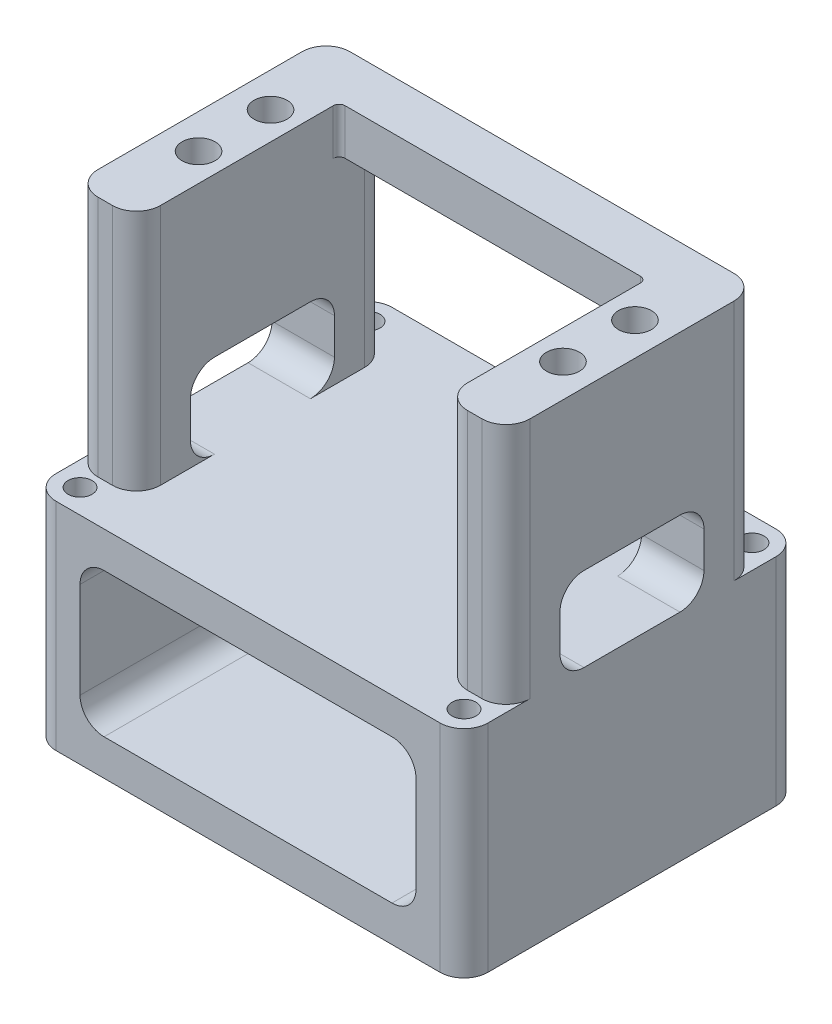
from build123d import *

# Parameters (mm, degrees)
SKETCH1_W           = 57.15
SKETCH1_H           = 38.1
SKETCH1_W_2         = 40.64
SKETCH1_H_2         = 26.035
BOSS_EXTRUDE1_DEPTH = 16.66875
CUT_EXTRUDE1_DEPTH  = 30.95625
SKETCH5_W           = 19.05
SKETCH5_H           = 11.1125
CUT_EXTRUDE2_DEPTH  = 57.15
SKETCH6_R           = 2.1828125
CUT_EXTRUDE3_DEPTH  = 19.05
SKETCH9_W           = 57.15
SKETCH9_H           = 28.575
BOSS_EXTRUDE2_DEPTH = 22.225
SKETCH10_R          = 1.5875
CUT_EXTRUDE4_DEPTH  = 28.575
CUT_EXTRUDE6_REACH  = 46.45
SKETCH12_W          = 44.45
SKETCH12_H          = 19.05
FILLET1_R           = 3.175


with BuildPart() as part:
    # Sketch1 → Boss-Extrude1 (new body, symmetric)
    with BuildSketch(Plane.XY):
        Rectangle(SKETCH1_W, SKETCH1_H)
        Rectangle(SKETCH1_W_2, SKETCH1_H_2, mode=Mode.SUBTRACT)
    extrude(amount=BOSS_EXTRUDE1_DEPTH, both=True)

    # Sketch3 → Cut-Extrude1 (cut)
    with BuildSketch(Plane(origin=(0, 19.05, 0), x_dir=(1, 0, 0), z_dir=(0, 1, 0))):
        with BuildLine():
            Line((20.32, -10.16), (20.32, 9.36625))
            ThreePointArc((20.32, 9.36625), (20.087516008, 9.927516008), (19.52625, 10.16))
            Line((19.52625, 10.16), (-19.52625, 10.16))
            ThreePointArc((-19.52625, 10.16), (-20.087516008, 9.927516008), (-20.32, 9.36625))
            Line((-20.32, 9.36625), (-20.32, -10.16))
            Line((-20.32, -10.16), (-20.32, -16.66875))
            Line((-20.32, -16.66875), (20.32, -16.66875))
            Line((20.32, -16.66875), (20.32, -10.16))
        make_face()
    extrude(amount=-CUT_EXTRUDE1_DEPTH, mode=Mode.SUBTRACT)

    # Sketch5 → Cut-Extrude2 (cut)
    with BuildSketch(Plane.ZY.offset(28.575)):
        with Locations((0, -7.46125)):
            Rectangle(SKETCH5_W, SKETCH5_H)
    extrude(amount=-CUT_EXTRUDE2_DEPTH, mode=Mode.SUBTRACT)

    # Sketch6 → Cut-Extrude3 (cut)
    with BuildSketch(Plane(origin=(0, 19.05, 0), x_dir=(1, 0, 0), z_dir=(0, 1, 0))):
        with Locations((-24.0109375, -4.7625)):
            Circle(SKETCH6_R)
        with Locations((-24.0109375, 4.7625)):
            Circle(SKETCH6_R)
        with Locations((24.209375, -4.7625)):
            Circle(SKETCH6_R)
        with Locations((24.209375, 4.7625)):
            Circle(SKETCH6_R)
    extrude(amount=-CUT_EXTRUDE3_DEPTH, mode=Mode.SUBTRACT)

    # Sketch9 → Boss-Extrude2 (add, symmetric)
    with BuildSketch(Plane.XY):
        with Locations((0, -27.305)):
            Rectangle(SKETCH9_W, SKETCH9_H)
    extrude(amount=BOSS_EXTRUDE2_DEPTH, both=True)

    # Sketch10 → Cut-Extrude4 (cut)
    with BuildSketch(Plane(origin=(0, -13.0175, 0), x_dir=(1, 0, 0), z_dir=(0, 1, 0))):
        with Locations((-25.4, 19.05)):
            Circle(SKETCH10_R)
        with Locations((25.4, 19.05)):
            Circle(SKETCH10_R)
        with Locations((-25.4, -19.05)):
            Circle(SKETCH10_R)
        with Locations((25.4, -19.05)):
            Circle(SKETCH10_R)
    extrude(amount=-CUT_EXTRUDE4_DEPTH, mode=Mode.SUBTRACT)

    # Sketch12 → Cut-Extrude6 (cut, up to next)
    with BuildSketch(Plane.XY.offset(22.225), mode=Mode.PRIVATE) as cut_extrude6_sk1:
        with Locations((0, -27.305)):
            Rectangle(SKETCH12_W, SKETCH12_H)
    cut_extrude6_tool1 = extrude(cut_extrude6_sk1.sketch, amount=-CUT_EXTRUDE6_REACH, mode=Mode.PRIVATE) & part.part
    add(cut_extrude6_tool1.solids().sort_by_distance((0, -27.305, 22.225))[0], mode=Mode.SUBTRACT)

    # Fillet1
    fillet1_edges = [part.edges().sort_by_distance(p)[0] for p in [
        (28.575, 3.01625, -16.66875),
        (28.575, 3.01625, 16.66875),
        (-28.575, -27.305, -22.225),
        (28.575, -27.305, -22.225),
        (-28.575, -27.305, 22.225),
        (28.575, -27.305, 22.225),
        (20.32, 0, -16.66875),
        (-22.225, -36.83, 0),
        (-22.225, -17.78, 0),
        (22.225, -17.78, 0),
        (22.225, -36.83, 0),
        (-20.32, 0, -16.66875),
        (20.32, 3.01625, 16.66875),
        (-20.32, 3.01625, 16.66875),
        (-28.575, 3.01625, 16.66875),
        (-28.575, 3.01625, -16.66875),
        (24.4475, -13.0175, 9.525),
        (24.4475, -1.905, -9.525),
        (24.4475, -1.905, 9.525),
        (24.4475, -13.0175, -9.525),
        (-24.4475, -1.905, 9.525),
        (-24.4475, -13.0175, 9.525),
        (-24.4475, -13.0175, -9.525),
        (-24.4475, -1.905, -9.525),
    ]]
    fillet(fillet1_edges, radius=FILLET1_R)


solid = part.part
